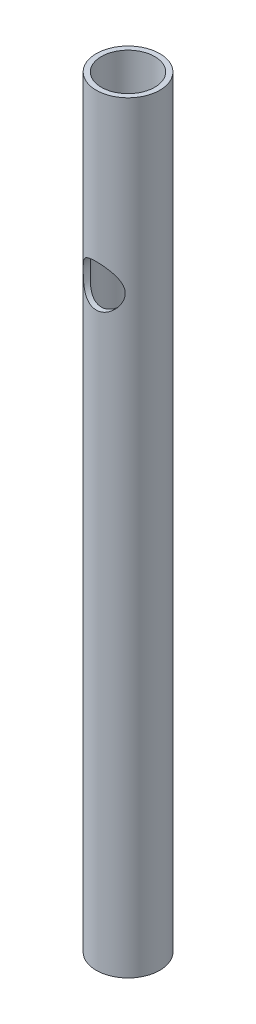
from build123d import *

# Parameters (mm, degrees)
SKETCH1_W               = 3
SKETCH1_H               = 450
SKETCH2_R               = 12.4
CUT_EXTRUDE1_DEPTH      = 19.75
CUT_EXTRUDE1_DEPTH_BACK = 19.75


with BuildPart() as part:
    # Sketch1 → Revolve-Thin1 (revolve)
    with BuildSketch(Plane.XY):
        with Locations((-17.25, 225)):
            Rectangle(SKETCH1_W, SKETCH1_H)
    revolve(axis=Axis((0, 0, 0), (0, 1, 0)))

    # Sketch2 → Cut-Extrude1 (cut, two sides)
    with BuildSketch(Plane.XY) as cut_extrude1_sk:
        with Locations((0, 350)):
            Circle(SKETCH2_R)
    extrude(amount=CUT_EXTRUDE1_DEPTH, mode=Mode.SUBTRACT)
    extrude(cut_extrude1_sk.sketch, amount=-CUT_EXTRUDE1_DEPTH_BACK, mode=Mode.SUBTRACT)


solid = part.part
